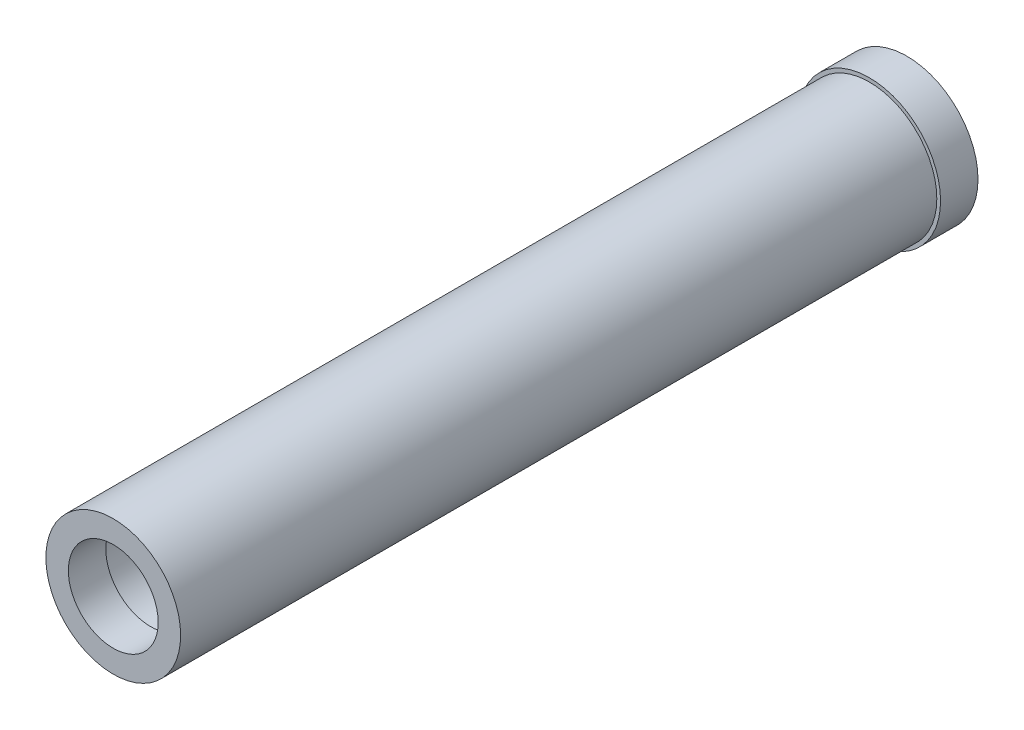
from build123d import *

# Parameters (mm, degrees)
SKETCH1_R           = 19
BOSS_EXTRUDE1_DEPTH = 10
SKETCH1_3_R         = 18
BOSS_EXTRUDE2_DEPTH = 212
SKETCH2_R           = 13
CUT_EXTRUDE1_DEPTH  = 200
SKETCH3_R           = 13
SKETCH3_R_2         = 12
BOSS_EXTRUDE3_DEPTH = 10


with BuildPart() as part:
    # Sketch1 → Boss-Extrude1 (new body)
    with BuildSketch(Plane.XY):
        Circle(SKETCH1_R)
    extrude(amount=BOSS_EXTRUDE1_DEPTH)

    # Sketch1_3 → Boss-Extrude2 (add)
    with BuildSketch(Plane.XY):
        Circle(SKETCH1_3_R)
    extrude(amount=BOSS_EXTRUDE2_DEPTH)

    # Sketch2 → Cut-Extrude1 (cut)
    with BuildSketch(Plane.XY.offset(212)):
        Circle(SKETCH2_R)
    extrude(amount=-CUT_EXTRUDE1_DEPTH, mode=Mode.SUBTRACT)

    # Sketch3 → Boss-Extrude3 (add)
    with BuildSketch(Plane.XY.offset(212)):
        Circle(SKETCH3_R)
        Circle(SKETCH3_R_2, mode=Mode.SUBTRACT)
    extrude(amount=-BOSS_EXTRUDE3_DEPTH)


solid = part.part
